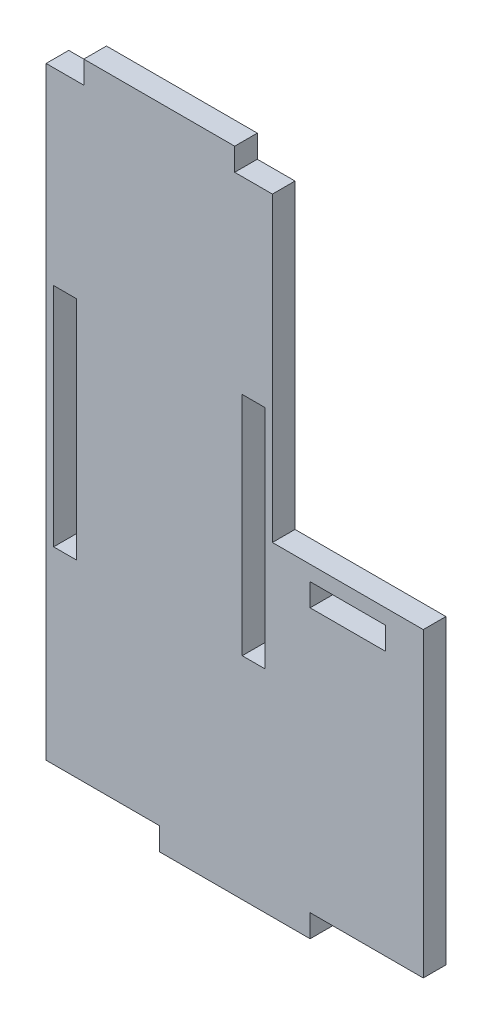
from build123d import *

# Parameters (mm, degrees)
SKETCH1_W           = 3
SKETCH1_H           = 30
SKETCH1_W_2         = 10
SKETCH1_H_2         = 3
BOSS_EXTRUDE2_DEPTH = 1.5


with BuildPart() as part:
    # Sketch1 → Boss-Extrude2 (new body, symmetric)
    with BuildSketch(Plane.XY):
        Polygon((10, 40), (15, 40), (15, 0), (35, 0), (35, -40), (20, -40), (20, -43), (0, -43), (0, -40), (-15, -40), (-15, 40), (-10, 40), (-10, 43), (10, 43), align=None)
        with Locations((-12.5, 0)):
            Rectangle(SKETCH1_W, SKETCH1_H, mode=Mode.SUBTRACT)
        with Locations((12.5, 0)):
            Rectangle(SKETCH1_W, SKETCH1_H, mode=Mode.SUBTRACT)
        with Locations((25, -3.5)):
            Rectangle(SKETCH1_W_2, SKETCH1_H_2, mode=Mode.SUBTRACT)
    extrude(amount=BOSS_EXTRUDE2_DEPTH, both=True)


solid = part.part
